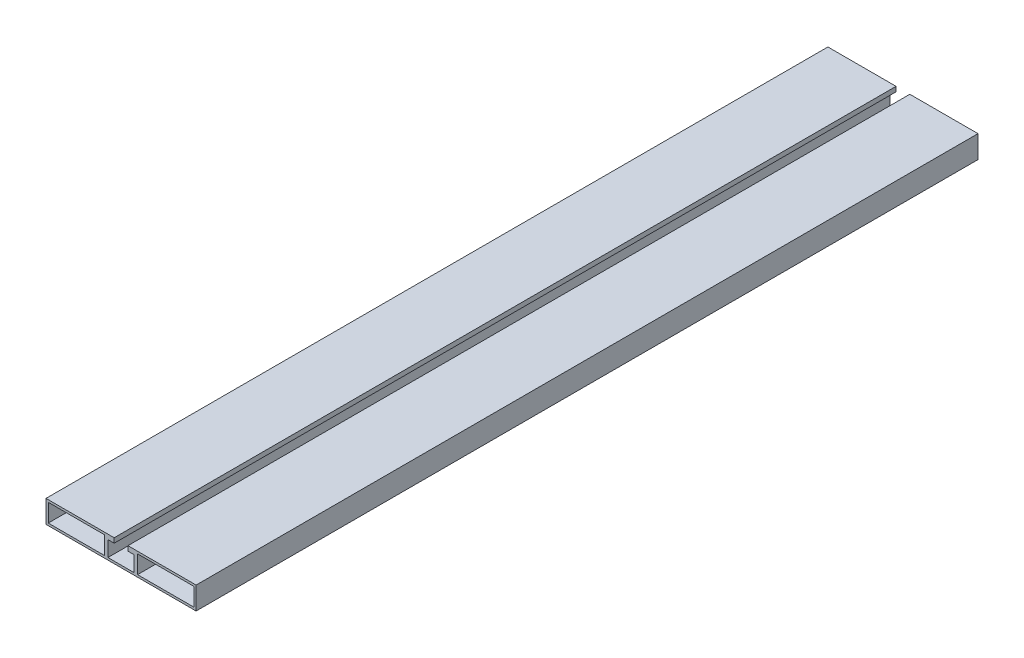
from build123d import *

# Parameters (mm, degrees)
SKETCH1_W                  = 45
SKETCH1_H                  = 14.4
BOSS_EXTRUDE1_DEPTH        = 625
F_5_2_5_2_DIAMETER_HOLE1_D = 5.2


with BuildPart() as part:
    # Sketch1 → Boss-Extrude1 (new body)
    with BuildSketch(Plane.XY):
        Polygon((-10.5, 5.2), (-10.5, -7.2), (10.5, -7.2), (10.5, 5.2), (5.5, 5.2), (5.5, 9), (60, 9), (60, -9), (-60, -9), (-60, 9), (-5.5, 9), (-5.5, 5.2), align=None)
        with Locations((-35.7, 0)):
            Rectangle(SKETCH1_W, SKETCH1_H, mode=Mode.SUBTRACT)
        with Locations((35.7, 0)):
            Rectangle(SKETCH1_W, SKETCH1_H, mode=Mode.SUBTRACT)
    extrude(amount=BOSS_EXTRUDE1_DEPTH)

    # Ø5.2 (5.2) Diameter Hole1 (through all)
    with Locations(Plane(origin=(0, -9, 0), x_dir=(-1, 0, 0), z_dir=(0, -1, 0))):
        with Locations((0, -22), (0, -603)):
            Hole(F_5_2_5_2_DIAMETER_HOLE1_D / 2)


solid = part.part
